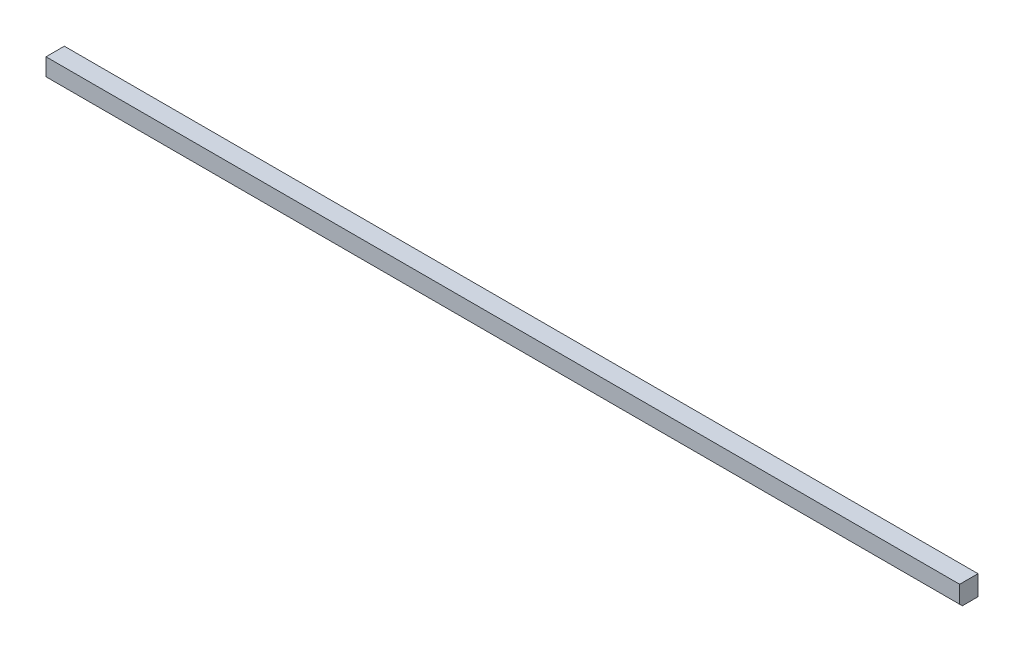
from build123d import *

# Parameters (mm, degrees)
SKETCH1_W           = 869.95
SKETCH1_H           = 17.4625
BOSS_EXTRUDE1_DEPTH = 19.05
CHAMFER1_SIZE       = 2.54


with BuildPart() as part:
    # Sketch1 → Boss-Extrude1 (new body)
    with BuildSketch(Plane(origin=(0, 0, 0), x_dir=(1, 0, 0), z_dir=(0, 1, 0))):
        with Locations((434.975, 8.73125)):
            Rectangle(SKETCH1_W, SKETCH1_H)
    extrude(amount=BOSS_EXTRUDE1_DEPTH)

    # Chamfer1
    chamfer1_edges = [part.edges().sort_by_distance(p)[0] for p in [
        (434.975, 0, 0),
    ]]
    chamfer(chamfer1_edges, length=CHAMFER1_SIZE)


solid = part.part
